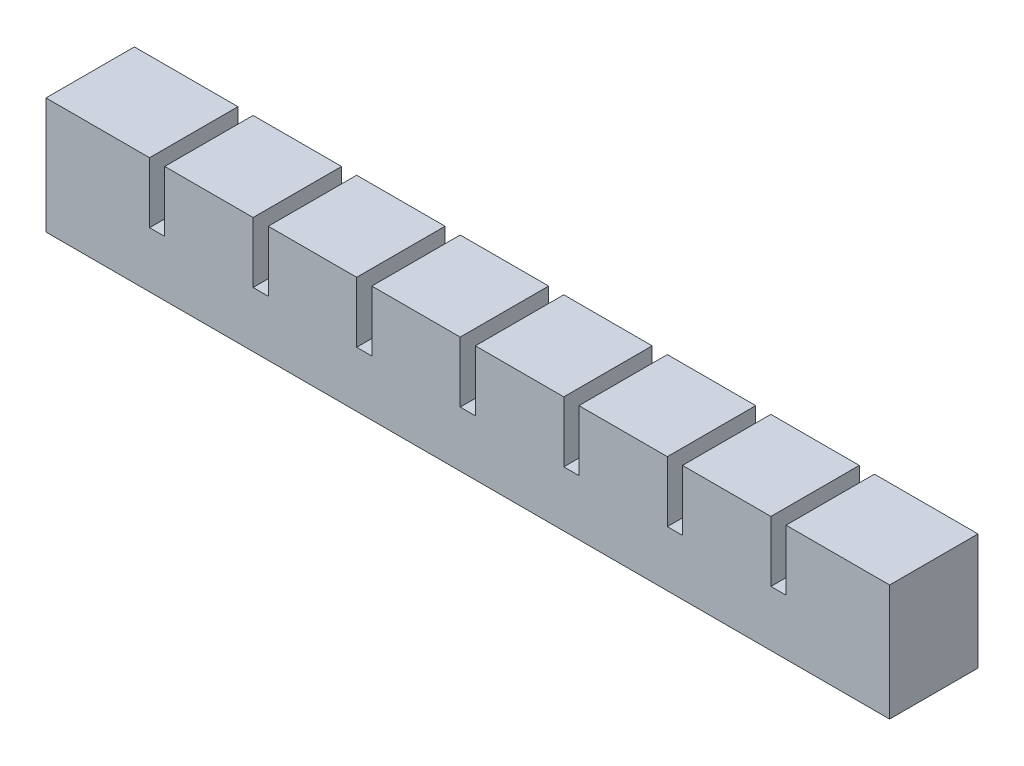
from build123d import *

# Parameters (mm, degrees)
SKETCH1_W           = 17.5
SKETCH1_H           = 17.5
BOSS_EXTRUDE1_DEPTH = 17.5
SKETCH2_W           = 6.5
SKETCH2_H           = 6.5
CUT_EXTRUDE1_DEPTH  = 12
SKETCH3_W           = 17.5
SKETCH3_H           = 5.5
BOSS_EXTRUDE2_DEPTH = 3
LPATTERN1_COUNT     = 8
LPATTERN1_PITCH     = 20.5
SKETCH4_W           = 17.5
SKETCH4_H           = 12
BOSS_EXTRUDE3_DEPTH = 3
SKETCH5_W           = 17.5
SKETCH5_H           = 17.5
BOSS_EXTRUDE4_DEPTH = 3
SKETCH6_W           = 137
SKETCH6_H           = 2
CUT_EXTRUDE2_DEPTH  = 2
SKETCH7_W           = 167
SKETCH7_H           = 17.5
BOSS_EXTRUDE5_DEPTH = 5.5


with BuildPart() as part:
    # Sketch1 → Boss-Extrude1 (new body)
    with BuildSketch(Plane.XY):
        with Locations((8.75, 8.75)):
            Rectangle(SKETCH1_W, SKETCH1_H)
    extrude(amount=BOSS_EXTRUDE1_DEPTH)

    # Sketch2 → Cut-Extrude1 (cut)
    with BuildSketch(Plane.XZ):
        with Locations((8.75, 8.75)):
            Rectangle(SKETCH2_W, SKETCH2_H)
    extrude(amount=-CUT_EXTRUDE1_DEPTH, mode=Mode.SUBTRACT)

    # Sketch3 → Boss-Extrude2 (add)
    with BuildSketch(Plane(origin=(17.5, 0, 0), x_dir=(0, 0, -1), z_dir=(1, 0, 0))):
        with Locations((-8.75, 2.75)):
            Rectangle(SKETCH3_W, SKETCH3_H)
    extrude(amount=BOSS_EXTRUDE2_DEPTH)


with BuildPart() as lpattern1_1:
    # LPattern1: pattern copy
    add(part.part.moved(Location(Vector(1, 0, 0) * (1 * LPATTERN1_PITCH))))


with BuildPart() as lpattern1_2:
    # LPattern1: pattern copy
    add(part.part.moved(Location(Vector(1, 0, 0) * (2 * LPATTERN1_PITCH))))


with BuildPart() as lpattern1_3:
    # LPattern1: pattern copy
    add(part.part.moved(Location(Vector(1, 0, 0) * (3 * LPATTERN1_PITCH))))


with BuildPart() as lpattern1_4:
    # LPattern1: pattern copy
    add(part.part.moved(Location(Vector(1, 0, 0) * (4 * LPATTERN1_PITCH))))


with BuildPart() as lpattern1_5:
    # LPattern1: pattern copy
    add(part.part.moved(Location(Vector(1, 0, 0) * (5 * LPATTERN1_PITCH))))


with BuildPart() as lpattern1_6:
    # LPattern1: pattern copy
    add(part.part.moved(Location(Vector(1, 0, 0) * (6 * LPATTERN1_PITCH))))


with BuildPart() as lpattern1_7:
    # LPattern1: pattern copy
    add(part.part.moved(Location(Vector(1, 0, 0) * (7 * LPATTERN1_PITCH))))


with BuildPart() as lpattern1_1_1:
    add(lpattern1_1.part)

    # Combine1: union LPattern1_2, LPattern1_3, LPattern1_4, LPattern1_5, part, LPattern1_6, LPattern1_7
    add(lpattern1_2.part)
    add(lpattern1_3.part)
    add(lpattern1_4.part)
    add(lpattern1_5.part)
    add(part.part)
    add(lpattern1_6.part)
    add(lpattern1_7.part)

    # Sketch4 → Boss-Extrude3 (add)
    with BuildSketch(Plane(origin=(161, 0, 0), x_dir=(0, 0, -1), z_dir=(1, 0, 0))):
        with Locations((-8.75, 11.5)):
            Rectangle(SKETCH4_W, SKETCH4_H)
    extrude(amount=BOSS_EXTRUDE3_DEPTH)

    # Sketch5 → Boss-Extrude4 (add)
    with BuildSketch(Plane.ZY):
        with Locations((8.75, 8.75)):
            Rectangle(SKETCH5_W, SKETCH5_H)
    extrude(amount=BOSS_EXTRUDE4_DEPTH)

    # Sketch6 → Cut-Extrude2 (cut)
    with BuildSketch(Plane.XZ):
        with Locations((80.5, 8.75)):
            Rectangle(SKETCH6_W, SKETCH6_H)
    extrude(amount=-CUT_EXTRUDE2_DEPTH, mode=Mode.SUBTRACT)

    # Sketch7 → Boss-Extrude5 (add)
    with BuildSketch(Plane.XZ):
        with Locations((80.5, 8.75)):
            Rectangle(SKETCH7_W, SKETCH7_H)
    extrude(amount=BOSS_EXTRUDE5_DEPTH)


solid = lpattern1_1_1.part
